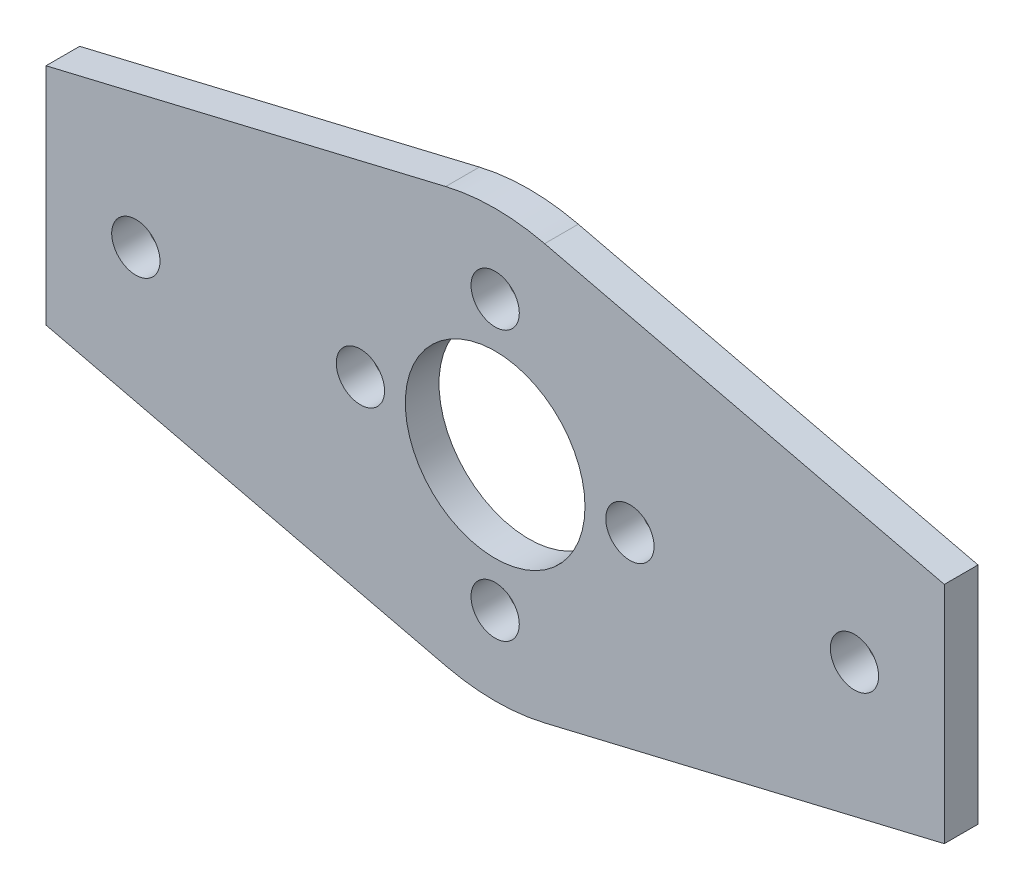
from build123d import *

# Parameters (mm, degrees)
SKETCH1_R      = 2.15
SKETCH1_R_2    = 8
EXTRUDE1_DEPTH = 3


with BuildPart() as part:
    # Sketch1 → Extrude1 (new body)
    with BuildSketch(Plane.XY):
        with BuildLine():
            Line((-65.365803698, -264.741816005), (-65.365803698, -284.741816005))
            Line((-65.365803698, -284.741816005), (-29.77018823, -293.224277878))
            ThreePointArc((-29.77018823, -293.224277878), (-25.365803698, -293.741816005), (-20.961419166, -293.224277878))
            Line((-20.961419166, -293.224277878), (14.634196302, -284.741816005))
            Line((14.634196302, -284.741816005), (14.634196302, -264.741816005))
            Line((14.634196302, -264.741816005), (-20.961419166, -256.259354131))
            ThreePointArc((-20.961419166, -256.259354131), (-25.365803698, -255.741816005), (-29.77018823, -256.259354131))
            Line((-29.77018823, -256.259354131), (-65.365803698, -264.741816005))
        make_face()
        with Locations((-57.365803698, -274.741816005)):
            Circle(SKETCH1_R, mode=Mode.SUBTRACT)
        with Locations((-37.365803698, -274.741816005)):
            Circle(SKETCH1_R, mode=Mode.SUBTRACT)
        with Locations((-13.365803698, -274.741816005)):
            Circle(SKETCH1_R, mode=Mode.SUBTRACT)
        with Locations((6.634196302, -274.741816005)):
            Circle(SKETCH1_R, mode=Mode.SUBTRACT)
        with Locations((-25.365803698, -274.741816005)):
            Circle(SKETCH1_R_2, mode=Mode.SUBTRACT)
        with Locations((-25.365803698, -262.741816005)):
            Circle(SKETCH1_R, mode=Mode.SUBTRACT)
        with Locations((-25.365803698, -286.741816005)):
            Circle(SKETCH1_R, mode=Mode.SUBTRACT)
    extrude(amount=EXTRUDE1_DEPTH)


solid = part.part
